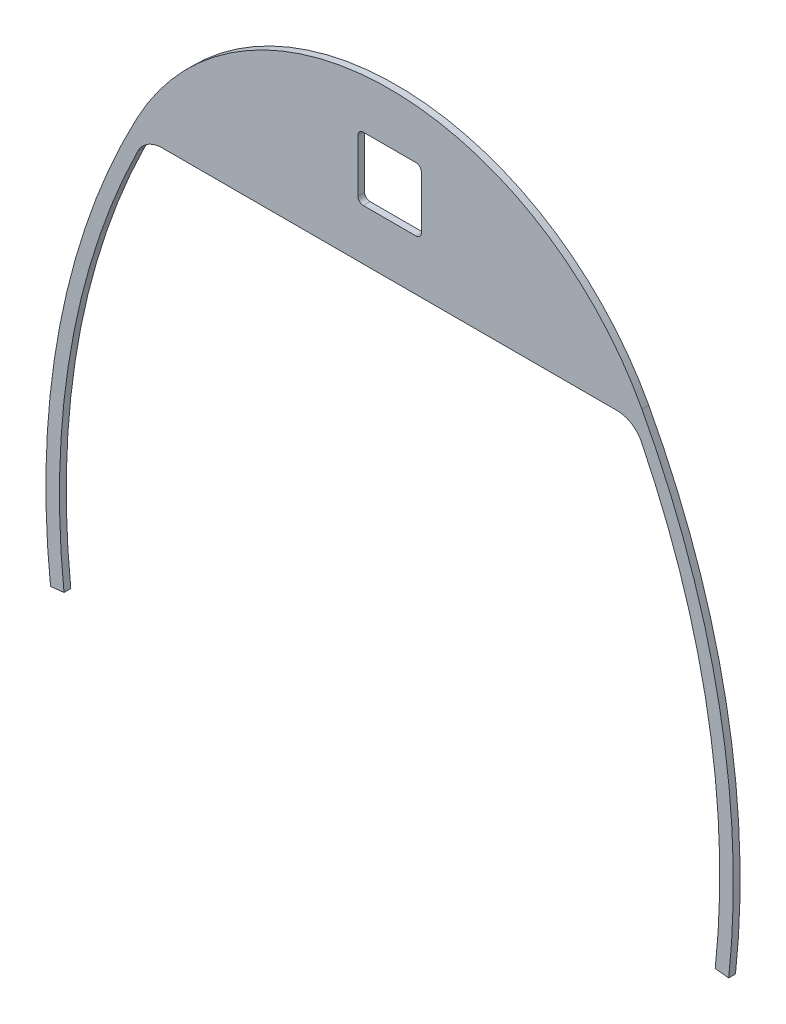
from build123d import *

# Parameters (mm, degrees)
BOSS_EXTRUDE1_DEPTH = 3.175
CUT_EXTRUDE1_REACH  = 325.245
SKETCH2_W           = 29.718
SKETCH2_H           = 29.718
FILLET1_R           = 2.54
FILLET2_R           = 12.7


with BuildPart() as part:
    # Sketch1 → Boss-Extrude1 (new body)
    with BuildSketch(Plane.XY):
        with BuildLine():
            ThreePointArc((118.128585461, 209.55), (0, 280.345753402), (-118.128585461, 209.55))
            ThreePointArc((-118.128585461, 209.55), (-154.323359707, 107.497469491), (-158.711897248, -0.694588462))
            Line((-158.711897248, -0.694588462), (-152.4, 0))
            ThreePointArc((-152.4, 0), (-148.443103792, 104.429956961), (-114.3, 203.2))
            Line((-114.3, 203.2), (114.3, 203.2))
            ThreePointArc((114.3, 203.2), (148.443103792, 104.429956961), (152.4, 0))
            Line((152.4, 0), (158.711897248, -0.694588462))
            ThreePointArc((158.711897248, -0.694588462), (154.323359707, 107.497469491), (118.128585461, 209.55))
        make_face()
    extrude(amount=BOSS_EXTRUDE1_DEPTH)

    # Sketch2 → Cut-Extrude1 (cut, up to next)
    with BuildSketch(Plane.XY.offset(3.175), mode=Mode.PRIVATE) as cut_extrude1_sk1:
        with Locations((0, 241.772876701)):
            Rectangle(SKETCH2_W, SKETCH2_H)
    cut_extrude1_tool1 = extrude(cut_extrude1_sk1.sketch, amount=-CUT_EXTRUDE1_REACH, mode=Mode.PRIVATE) & part.part
    add(cut_extrude1_tool1.solids().sort_by_distance((0, 241.772877, 3.175))[0], mode=Mode.SUBTRACT)

    # Fillet1
    fillet1_edges = [part.edges().sort_by_distance(p)[0] for p in [
        (14.859, 226.913876701, 1.5875),
        (14.859, 256.631876701, 1.5875),
        (-14.859, 256.631876701, 1.5875),
        (-14.859, 226.913876701, 1.5875),
    ]]
    fillet(fillet1_edges, radius=FILLET1_R)

    # Fillet2
    fillet2_edges = [part.edges().sort_by_distance(p)[0] for p in [
        (114.3, 203.2, 1.5875),
        (-114.3, 203.2, 1.5875),
    ]]
    fillet(fillet2_edges, radius=FILLET2_R)


solid = part.part
